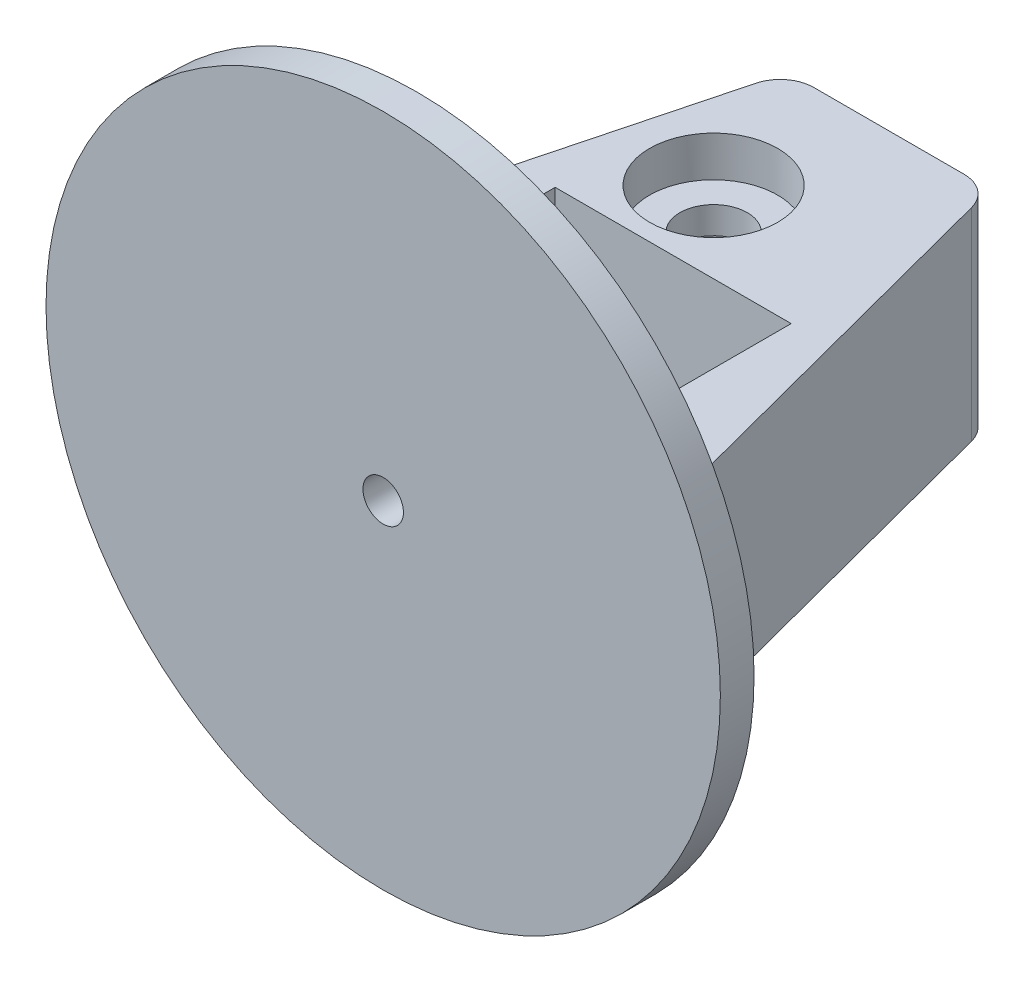
from build123d import *

# Parameters (mm, degrees)
BOSS_EXTRUDE1_DEPTH = 40
SKETCH9_R           = 9.5
CUT_EXTRUDE5_DEPTH  = 20
SKETCH10_R          = 5
CUT_EXTRUDE6_DEPTH  = 21
SKETCH11_R          = 9.5
CUT_EXTRUDE7_DEPTH  = 16
SKETCH14_W          = 35
SKETCH14_H          = 20
CUT_EXTRUDE9_DEPTH  = 41
SKETCH15_R          = 3
CUT_EXTRUDE10_DEPTH = 25
SKETCH16_R          = 50
SKETCH16_R_2        = 3
BOSS_EXTRUDE3_DEPTH = 5
SKETCH17_W          = 69.206254994
SKETCH17_H          = 74.867048483
CUT_EXTRUDE11_DEPTH = 10
SKETCH18_R          = 1.5
CUT_EXTRUDE12_DEPTH = 10
SKETCH20_R          = 1.5
CUT_EXTRUDE13_DEPTH = 10


with BuildPart() as part:
    # Sketch1 → Boss-Extrude1 (new body)
    with BuildSketch(Plane(origin=(0, 0, 0), x_dir=(1, 0, 0), z_dir=(0, 1, 0))):
        with BuildLine():
            Line((-11.141347684, 70), (11.141347684, 70))
            ThreePointArc((11.141347684, 70), (14.196114062, 68.958333283), (15.978061054, 66.267360951))
            Line((15.978061054, 66.267360951), (33.342055813, 0))
            Line((33.342055813, 0), (-33.342055813, 0))
            Line((-33.342055813, 0), (-15.978061054, 66.267360951))
            ThreePointArc((-15.978061054, 66.267360951), (-14.196114062, 68.958333283), (-11.141347684, 70))
        make_face()
    extrude(amount=BOSS_EXTRUDE1_DEPTH)

    # Sketch9 → Cut-Extrude5 (cut)
    with BuildSketch(Plane.XZ):
        with Locations((-6, -50)):
            Circle(SKETCH9_R)
    extrude(amount=-CUT_EXTRUDE5_DEPTH, mode=Mode.SUBTRACT)

    # Sketch10 → Cut-Extrude6 (cut, through all)
    with BuildSketch(Plane.XZ.offset(-20)):
        with Locations((-6, -50)):
            Circle(SKETCH10_R)
    extrude(amount=-CUT_EXTRUDE6_DEPTH, mode=Mode.SUBTRACT)

    # Sketch11 → Cut-Extrude7 (cut)
    with BuildSketch(Plane(origin=(0, 40, 0), x_dir=(1, 0, 0), z_dir=(0, 1, 0))):
        with Locations((-6, 50)):
            Circle(SKETCH11_R)
    extrude(amount=-CUT_EXTRUDE7_DEPTH, mode=Mode.SUBTRACT)

    # Sketch14 → Cut-Extrude9 (cut, through all)
    with BuildSketch(Plane(origin=(0, 40, 0), x_dir=(1, 0, 0), z_dir=(0, 1, 0))):
        with Locations((0, 28)):
            Rectangle(SKETCH14_W, SKETCH14_H)
    extrude(amount=-CUT_EXTRUDE9_DEPTH, mode=Mode.SUBTRACT)

    # Sketch15 → Cut-Extrude10 (cut)
    with BuildSketch(Plane.XY):
        with Locations((0, 20)):
            Circle(SKETCH15_R)
    extrude(amount=-CUT_EXTRUDE10_DEPTH, mode=Mode.SUBTRACT)

    # Sketch16 → Boss-Extrude3 (add)
    with BuildSketch(Plane.XY):
        with Locations((0, 20)):
            Circle(SKETCH16_R)
        with Locations((0, 20)):
            Circle(SKETCH16_R_2, mode=Mode.SUBTRACT)
    extrude(amount=BOSS_EXTRUDE3_DEPTH)

    # Sketch17 → Cut-Extrude11 (cut)
    with BuildSketch(Plane(origin=(0, 40, 0), x_dir=(1, 0, 0), z_dir=(0, 1, 0))):
        with Locations((1.261071684, 37.433524242)):
            Rectangle(SKETCH17_W, SKETCH17_H)
    extrude(amount=-CUT_EXTRUDE11_DEPTH, mode=Mode.SUBTRACT)

    # Sketch18 → Cut-Extrude12 (cut)
    with BuildSketch(Plane.XZ):
        with Locations((-1.350189987, -64.85)):
            Circle(SKETCH18_R)
        with Locations((-11.350189987, -64.85)):
            Circle(SKETCH18_R)
    extrude(amount=-CUT_EXTRUDE12_DEPTH, mode=Mode.SUBTRACT)

    # Sketch20 → Cut-Extrude13 (cut)
    with BuildSketch(Plane.XZ):
        with Locations((-11.350189987, -14.35)):
            Circle(SKETCH20_R)
        with Locations((-1.350189987, -14.35)):
            Circle(SKETCH20_R)
    extrude(amount=-CUT_EXTRUDE13_DEPTH, mode=Mode.SUBTRACT)


solid = part.part
